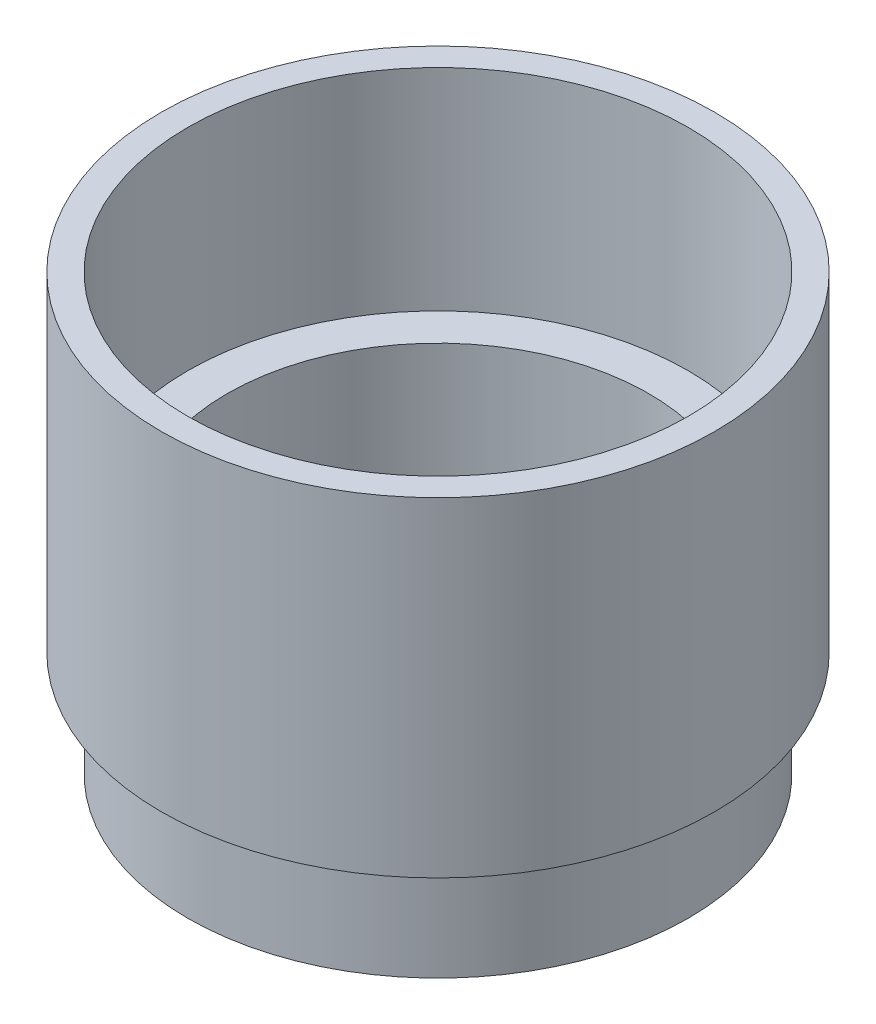
from build123d import *

# Parameters (mm, degrees)
CUT_EXTRUDE1_DEPTH = 5.08


with BuildPart() as part:
    # Sketch1 → Revolve1 (revolve)
    with BuildSketch(Plane.XY):
        Polygon((0, -44.45), (25.4, -44.45), (25.4, -25.4), (30.1625, -25.4), (30.1625, 0), (33.3375, 0), (33.3375, -39.6875), (30.1625, -39.6875), (30.1625, -52.3875), (0, -52.3875), align=None)
    revolve(axis=Axis((0, -44.45, 0), (0, -1, 0)))

    # Sketch2 → Cut-Extrude1 (cut)
    with BuildSketch(Plane(origin=(0, -44.45, 0), x_dir=(1, 0, 0), z_dir=(0, 1, 0))):
        with BuildLine():
            Line((12.7, -15.875), (-12.7, -15.875))
            ThreePointArc((-12.7, -15.875), (-14.94506403, -14.94506403), (-15.875, -12.7))
            Line((-15.875, -12.7), (-15.875, 12.7))
            ThreePointArc((-15.875, 12.7), (-14.94506403, 14.94506403), (-12.7, 15.875))
            Line((-12.7, 15.875), (12.7, 15.875))
            ThreePointArc((12.7, 15.875), (14.94506403, 14.94506403), (15.875, 12.7))
            Line((15.875, 12.7), (15.875, -12.7))
            ThreePointArc((15.875, -12.7), (14.94506403, -14.94506403), (12.7, -15.875))
        make_face()
    extrude(amount=-CUT_EXTRUDE1_DEPTH, mode=Mode.SUBTRACT)


solid = part.part
